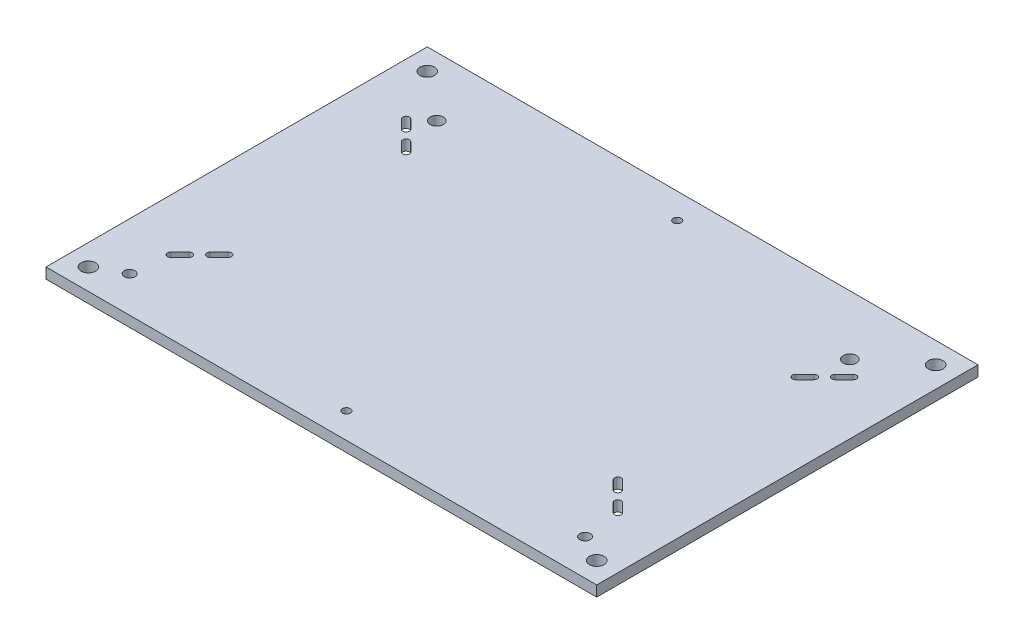
from build123d import *

# Parameters (mm, degrees)
SKETCH1_W                      = 330.2
SKETCH1_H                      = 228.6
BASE_PLATE_DEPTH               = 6.35
SLOTS_DEPTH                    = 7.35
FEET_CONNECTION_HOLE_D         = 8.7376
F_1_4_0_25_DIAMETER_HOLE1_D    = 6.35
F_5_16_0_3125_DIAMETER_HOLE1_D = 7.9375
ESD_CONNECTION_HOLE_D          = 4.7625


with BuildPart() as part:
    # Sketch1 → base plate (new body)
    with BuildSketch(Plane(origin=(0, 0, 0), x_dir=(1, 0, 0), z_dir=(0, 1, 0))):
        with Locations((165.1, -114.3)):
            Rectangle(SKETCH1_W, SKETCH1_H)
    extrude(amount=-BASE_PLATE_DEPTH)

    # Sketch3 → slots (cut, through all)
    with BuildSketch(Plane(origin=(0, 0, 0), x_dir=(1, 0, 0), z_dir=(0, 1, 0))):
        with BuildLine():
            ThreePointArc((37.882935507, -47.754508291), (37.882935507, -50.582935507), (35.054508291, -50.582935507))
            Line((35.054508291, -50.582935507), (29.666354619, -45.194781834))
            ThreePointArc((29.666354619, -45.194781834), (29.666354619, -42.366354619), (32.494781834, -42.366354619))
            Line((32.494781834, -42.366354619), (37.882935507, -47.754508291))
        make_face()
        with BuildLine():
            Line((297.705218166, -42.366354619), (292.317064493, -47.754508291))
            ThreePointArc((292.317064493, -47.754508291), (292.317064493, -50.582935507), (295.145491709, -50.582935507))
            Line((295.145491709, -50.582935507), (300.533645381, -45.194781834))
            ThreePointArc((300.533645381, -45.194781834), (300.533645381, -42.366354619), (297.705218166, -42.366354619))
        make_face()
        with BuildLine():
            Line((283.336808372, -62.391618843), (288.724962045, -57.00346517))
            ThreePointArc((288.724962045, -57.00346517), (288.724962045, -54.175037955), (285.89653483, -54.175037955))
            Line((285.89653483, -54.175037955), (280.508381157, -59.563191628))
            ThreePointArc((280.508381157, -59.563191628), (280.508381157, -62.391618843), (283.336808372, -62.391618843))
        make_face()
        with BuildLine():
            ThreePointArc((288.724962045, -171.59653483), (288.724962045, -174.424962045), (285.89653483, -174.424962045))
            Line((285.89653483, -174.424962045), (280.508381157, -169.036808372))
            ThreePointArc((280.508381157, -169.036808372), (280.508381157, -166.208381157), (283.336808372, -166.208381157))
            Line((283.336808372, -166.208381157), (288.724962045, -171.59653483))
        make_face()
        with BuildLine():
            ThreePointArc((292.317064493, -180.845491709), (292.317064493, -178.017064493), (295.145491709, -178.017064493))
            Line((295.145491709, -178.017064493), (300.533645381, -183.405218166))
            ThreePointArc((300.533645381, -183.405218166), (300.533645381, -186.233645381), (297.705218166, -186.233645381))
            Line((297.705218166, -186.233645381), (292.317064493, -180.845491709))
        make_face()
        with BuildLine():
            Line((32.494781834, -186.233645381), (37.882935507, -180.845491709))
            ThreePointArc((37.882935507, -180.845491709), (37.882935507, -178.017064493), (35.054508291, -178.017064493))
            Line((35.054508291, -178.017064493), (29.666354619, -183.405218166))
            ThreePointArc((29.666354619, -183.405218166), (29.666354619, -186.233645381), (32.494781834, -186.233645381))
        make_face()
        with BuildLine():
            Line((46.863191628, -166.208381157), (41.475037955, -171.59653483))
            ThreePointArc((41.475037955, -171.59653483), (41.475037955, -174.424962045), (44.30346517, -174.424962045))
            Line((44.30346517, -174.424962045), (49.691618843, -169.036808372))
            ThreePointArc((49.691618843, -169.036808372), (49.691618843, -166.208381157), (46.863191628, -166.208381157))
        make_face()
        with BuildLine():
            Line((46.863191628, -62.391618843), (41.475037955, -57.00346517))
            ThreePointArc((41.475037955, -57.00346517), (41.475037955, -54.175037955), (44.30346517, -54.175037955))
            Line((44.30346517, -54.175037955), (49.691618843, -59.563191628))
            ThreePointArc((49.691618843, -59.563191628), (49.691618843, -62.391618843), (46.863191628, -62.391618843))
        make_face()
    extrude(amount=-SLOTS_DEPTH, mode=Mode.SUBTRACT)

    # Feet connection hole (through all)
    with Locations(Plane(origin=(0, 0, 0), x_dir=(1, 0, 0), z_dir=(0, 1, 0))):
        with Locations((12.7, -215.9), (317.5, -12.7), (317.5, -215.9), (12.7, -12.7)):
            Hole(FEET_CONNECTION_HOLE_D / 2)

    # 1/4 (0.25) Diameter Hole1 (through all)
    with Locations(Plane(origin=(0, 0, 0), x_dir=(1, 0, 0), z_dir=(0, 1, 0))):
        with Locations((28.575, -207.01), (301.625, -207.01)):
            Hole(F_1_4_0_25_DIAMETER_HOLE1_D / 2)

    # 5/16 (0.3125) Diameter Hole1 (through all)
    with Locations(Plane(origin=(0, 0, 0), x_dir=(1, 0, 0), z_dir=(0, 1, 0))):
        with Locations((41.275, -35.56), (288.925, -35.56)):
            Hole(F_5_16_0_3125_DIAMETER_HOLE1_D / 2)

    # ESD Connection hole (through all)
    with Locations(Plane(origin=(0, 0, 0), x_dir=(1, 0, 0), z_dir=(0, 1, 0))):
        with Locations((165.1, -15.24), (164.768662044, -213.266978445)):
            Hole(ESD_CONNECTION_HOLE_D / 2)


solid = part.part
